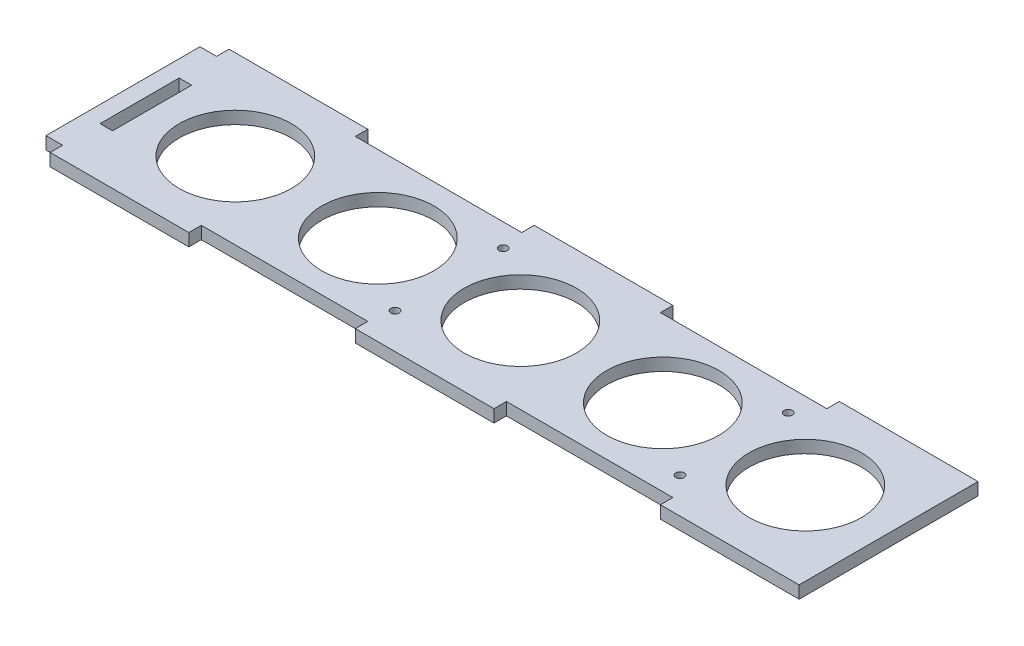
from build123d import *

# Parameters (mm, degrees)
SKETCH1_W           = 3
SKETCH1_H           = 19
SKETCH1_R           = 1
SKETCH1_R_2         = 13.5
BOSS_EXTRUDE1_DEPTH = 3


with BuildPart() as part:
    # Sketch1 → Boss-Extrude1 (new body)
    with BuildSketch(Plane(origin=(0, 0, 0), x_dir=(1, 0, 0), z_dir=(0, 1, 0))):
        Polygon((33.333333333, 21.5), (0, 21.5), (0, 18.5), (-4, 18.5), (-4, -18.5), (0, -18.5), (0, -21.5), (33.333333333, -21.5), (33.333333333, -18.5), (73.333333333, -18.5), (73.333333333, -21.5), (106.666666667, -21.5), (106.666666667, -18.5), (146.666666667, -18.5), (146.666666667, -21.5), (180, -21.5), (180, 21.5), (146.666666667, 21.5), (146.666666667, 18.5), (106.666666667, 18.5), (106.666666667, 21.5), (73.333333333, 21.5), (73.333333333, 18.5), (33.333333333, 18.5), align=None)
        with Locations((1.5, 0)):
            Rectangle(SKETCH1_W, SKETCH1_H, mode=Mode.SUBTRACT)
        with Locations((74.375, -13)):
            Circle(SKETCH1_R, mode=Mode.SUBTRACT)
        with Locations((142.875, -13)):
            Circle(SKETCH1_R, mode=Mode.SUBTRACT)
        with Locations((23, 0)):
            Circle(SKETCH1_R_2, mode=Mode.SUBTRACT)
        with Locations((57.25, 0)):
            Circle(SKETCH1_R_2, mode=Mode.SUBTRACT)
        with Locations((74.375, 13)):
            Circle(SKETCH1_R, mode=Mode.SUBTRACT)
        with Locations((91.5, 0)):
            Circle(SKETCH1_R_2, mode=Mode.SUBTRACT)
        with Locations((125.75, 0)):
            Circle(SKETCH1_R_2, mode=Mode.SUBTRACT)
        with Locations((160, 0)):
            Circle(SKETCH1_R_2, mode=Mode.SUBTRACT)
        with Locations((142.875, 13)):
            Circle(SKETCH1_R, mode=Mode.SUBTRACT)
    extrude(amount=BOSS_EXTRUDE1_DEPTH)


solid = part.part
